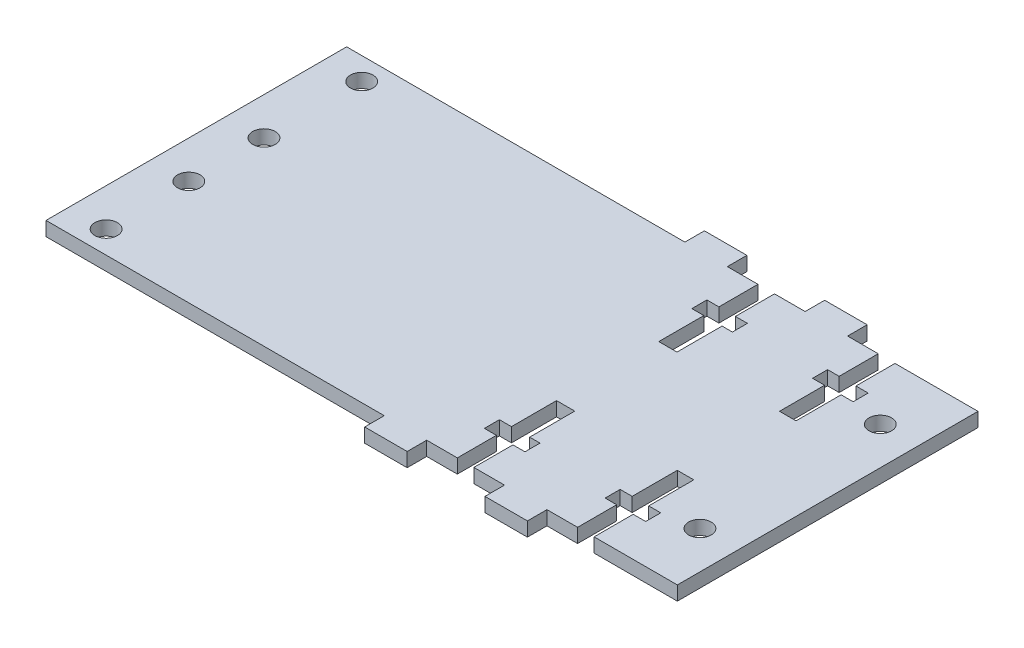
from build123d import *

# Parameters (mm, degrees)
BOSS_EXTRUDE1_DEPTH = 2.38125
SKETCH3_W           = 38.1
SKETCH3_H           = 50.8
SKETCH3_R           = 1.905
BOSS_EXTRUDE4_DEPTH = 2.38125
SKETCH7_W           = 33.02
SKETCH7_H           = 50.8
CUT_EXTRUDE3_DEPTH  = 3.38125
SKETCH8_R           = 1.905
CUT_EXTRUDE4_DEPTH  = 3.38125


with BuildPart() as part:
    # Sketch1 → Boss-Extrude1 (new body)
    with BuildSketch(Plane(origin=(0, 0, 0), x_dir=(1, 0, 0), z_dir=(0, 1, 0))):
        Polygon((107.95, -12.7), (107.95, 0), (107.95, 38.1), (60.905597294, 38.1), (60.905597294, 31.496), (62.977716984, 31.496), (62.977716984, 28.956), (60.945716984, 28.956), (60.945716984, 21.336), (58.151716984, 21.336), (58.151716984, 28.956), (56.119716984, 28.956), (56.119716984, 31.496), (58.07075, 31.496), (58.07075, 38.1), (52.8955, 38.1), (52.8955, 41.402), (45.72, 41.402), (45.72, 38.1), (40.54475, 38.1), (40.54475, 31.496), (42.57675, 31.496), (42.57675, 28.956), (40.82869895, 28.956), (40.82869895, 21.336), (37.75075, 21.336), (37.75075, 28.956), (35.71875, 28.956), (35.71875, 31.496), (37.75075, 31.496), (37.75075, 38.1), (32.5755, 38.1), (32.5755, 41.402), (25.4, 41.402), (25.4, 38.1), (6.35, 38.1), (6.35, -12.7), (25.4, -12.7), (25.4, -16.002), (32.5755, -16.002), (32.5755, -12.7), (37.75075, -12.7), (37.75075, -6.096), (35.71875, -6.096), (35.71875, -3.556), (37.75075, -3.556), (37.75075, 4.064), (40.82869895, 4.064), (40.82869895, -3.556), (42.57675, -3.556), (42.57675, -6.096), (40.54475, -6.096), (40.54475, -12.7), (45.72, -12.7), (45.72, -16.002), (52.8955, -16.002), (52.8955, -12.7), (58.07075, -12.7), (58.07075, -6.096), (56.119716984, -6.096), (56.119716984, -3.556), (58.151716984, -3.556), (58.151716984, 4.064), (60.945716984, 4.064), (60.945716984, -3.556), (62.977716984, -3.556), (62.977716984, -6.096), (60.86475, -6.096), (60.86475, -12.7), (66.04, -12.7), (73.2155, -12.7), (78.035770588, -12.7), (80.829770588, -12.7), align=None)
    extrude(amount=BOSS_EXTRUDE1_DEPTH)

    # Sketch3 → Boss-Extrude4 (add)
    with BuildSketch(Plane(origin=(0, 2.38125, 0), x_dir=(1, 0, 0), z_dir=(0, 1, 0))):
        with Locations((-12.7, 12.7)):
            Rectangle(SKETCH3_W, SKETCH3_H)
        with Locations((-25.4, -8.89)):
            Circle(SKETCH3_R, mode=Mode.SUBTRACT)
        with Locations((-25.4, 5.08)):
            Circle(SKETCH3_R, mode=Mode.SUBTRACT)
        with Locations((-25.4, 17.78)):
            Circle(SKETCH3_R, mode=Mode.SUBTRACT)
        with Locations((-25.4, 34.29)):
            Circle(SKETCH3_R, mode=Mode.SUBTRACT)
    extrude(amount=-BOSS_EXTRUDE4_DEPTH)

    # Sketch7 → Cut-Extrude3 (cut, through all)
    with BuildSketch(Plane(origin=(0, 2.38125, 0), x_dir=(1, 0, 0), z_dir=(0, 1, 0))):
        with Locations((91.44, 12.7)):
            Rectangle(SKETCH7_W, SKETCH7_H)
    extrude(amount=-CUT_EXTRUDE3_DEPTH, mode=Mode.SUBTRACT)

    # Sketch8 → Cut-Extrude4 (cut, through all)
    with BuildSketch(Plane(origin=(0, 2.38125, 0), x_dir=(1, 0, 0), z_dir=(0, 1, 0))):
        with Locations((68.58, -2.54)):
            Circle(SKETCH8_R)
        with Locations((68.58, 27.94)):
            Circle(SKETCH8_R)
    extrude(amount=-CUT_EXTRUDE4_DEPTH, mode=Mode.SUBTRACT)


solid = part.part
